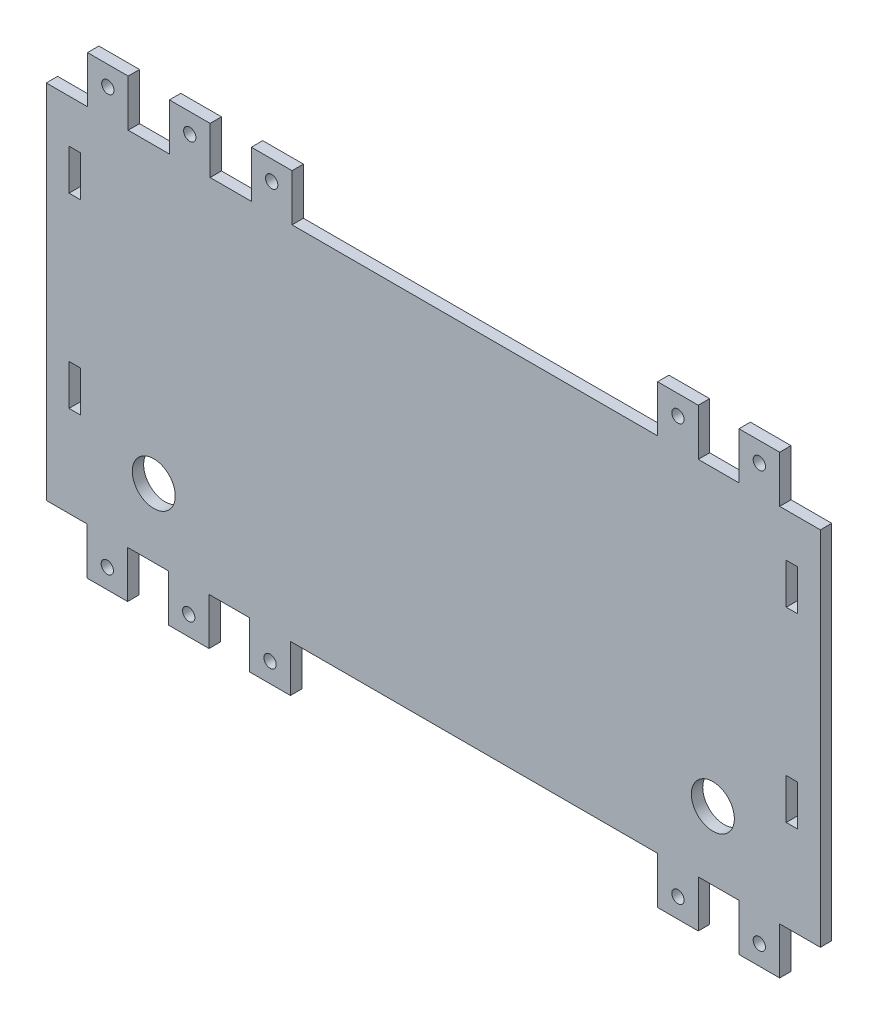
from build123d import *

# Parameters (mm, degrees)
SKETCH1_W               = 215.9
SKETCH1_H               = 127
BOSS_EXTRUDE1_DEPTH     = 3.175
SKETCH4_W               = 11.35
SKETCH4_H               = 13.0800094
SKETCH4_W_2             = 101.949970282
SKETCH4_W_3             = 11.50001
SKETCH4_W_4             = 102.400000282
CUT_EXTRUDE1_DEPTH      = 4.175
SKETCH5_R               = 6
CUT_EXTRUDE2_DEPTH      = 1
CUT_EXTRUDE2_DEPTH_BACK = 4.175
SKETCH6_R               = 1.7145
CUT_EXTRUDE3_DEPTH      = 4.175
SKETCH10_W              = 3.175
SKETCH10_H              = 11.34999
CUT_EXTRUDE4_DEPTH      = 3.175


with BuildPart() as part:
    # Sketch1 → Boss-Extrude1 (new body)
    with BuildSketch(Plane.XY):
        with Locations((60.172222222, -34.055555556)):
            Rectangle(SKETCH1_W, SKETCH1_H)
    extrude(amount=BOSS_EXTRUDE1_DEPTH)

    # Sketch4 → Cut-Extrude1 (cut, through all)
    with BuildSketch(Plane(origin=(0, 0, 0), x_dir=(-1, 0, 0), z_dir=(0, 0, -1))):
        with Locations((-162.447222222, 22.904439744)):
            Rectangle(SKETCH4_W, SKETCH4_H)
        with Locations((-139.747222222, 22.904439744)):
            Rectangle(SKETCH4_W, SKETCH4_H)
        with Locations((-71.747237175, 22.904439744)):
            Rectangle(SKETCH4_W_2, SKETCH4_H)
        with Locations((-3.672247128, 22.904439744)):
            Rectangle(SKETCH4_W_3, SKETCH4_H)
        with Locations((19.177762872, 22.904439744)):
            Rectangle(SKETCH4_W_3, SKETCH4_H)
        with Locations((42.027772778, 22.904439744)):
            Rectangle(SKETCH4_W_3, SKETCH4_H)
        with Locations((-162.447222222, -91.015550856)):
            Rectangle(SKETCH4_W, SKETCH4_H)
        with Locations((-139.747222222, -91.015550856)):
            Rectangle(SKETCH4_W, SKETCH4_H)
        with Locations((-71.522222175, -91.015550856)):
            Rectangle(SKETCH4_W_4, SKETCH4_H)
        with Locations((-3.297222034, -91.015550856)):
            Rectangle(SKETCH4_W, SKETCH4_H)
        with Locations((19.402777872, -91.015550856)):
            Rectangle(SKETCH4_W, SKETCH4_H)
        with Locations((42.102777778, -91.015550856)):
            Rectangle(SKETCH4_W, SKETCH4_H)
    extrude(amount=-CUT_EXTRUDE1_DEPTH, mode=Mode.SUBTRACT)

    # Sketch5 → Cut-Extrude2 (cut, two sides)
    with BuildSketch(Plane(origin=(0, 0, 0), x_dir=(-1, 0, 0), z_dir=(0, 0, -1))) as cut_extrude2_sk:
        with Locations((-138.137522222, -65.425546156)):
            Circle(SKETCH5_R)
        with Locations((17.793077778, -65.425546156)):
            Circle(SKETCH5_R)
    extrude(amount=CUT_EXTRUDE2_DEPTH, mode=Mode.SUBTRACT)
    extrude(cut_extrude2_sk.sketch, amount=-CUT_EXTRUDE2_DEPTH_BACK, mode=Mode.SUBTRACT)

    # Sketch6 → Cut-Extrude3 (cut, through all)
    with BuildSketch(Plane(origin=(0, 0, 0), x_dir=(-1, 0, 0), z_dir=(0, 0, -1))):
        with Locations((-151.097222222, 23.984435044)):
            Circle(SKETCH6_R)
        with Locations((-128.397222269, 23.984435044)):
            Circle(SKETCH6_R)
        with Locations((-15.097252081, 23.984435044)):
            Circle(SKETCH6_R)
        with Locations((7.752757872, 23.984435044)):
            Circle(SKETCH6_R)
        with Locations((30.602767825, 23.984435044)):
            Circle(SKETCH6_R)
        with Locations((-128.397222269, -92.095546156)):
            Circle(SKETCH6_R)
        with Locations((-151.097222222, -92.095546156)):
            Circle(SKETCH6_R)
        with Locations((-14.647222034, -92.095546156)):
            Circle(SKETCH6_R)
        with Locations((8.052777919, -92.095546156)):
            Circle(SKETCH6_R)
        with Locations((30.752777825, -92.095546156)):
            Circle(SKETCH6_R)
    extrude(amount=-CUT_EXTRUDE3_DEPTH, mode=Mode.SUBTRACT)

    # Sketch10 → Cut-Extrude4 (cut)
    with BuildSketch(Plane.XY.offset(3.175)):
        with Locations((-39.840277778, -1.410561156)):
            Rectangle(SKETCH10_W, SKETCH10_H)
        with Locations((-39.840277778, -53.400551156)):
            Rectangle(SKETCH10_W, SKETCH10_H)
        with Locations((160.184722222, -1.410561156)):
            Rectangle(SKETCH10_W, SKETCH10_H)
        with Locations((160.184722222, -53.400551156)):
            Rectangle(SKETCH10_W, SKETCH10_H)
    extrude(amount=-CUT_EXTRUDE4_DEPTH, mode=Mode.SUBTRACT)


solid = part.part
